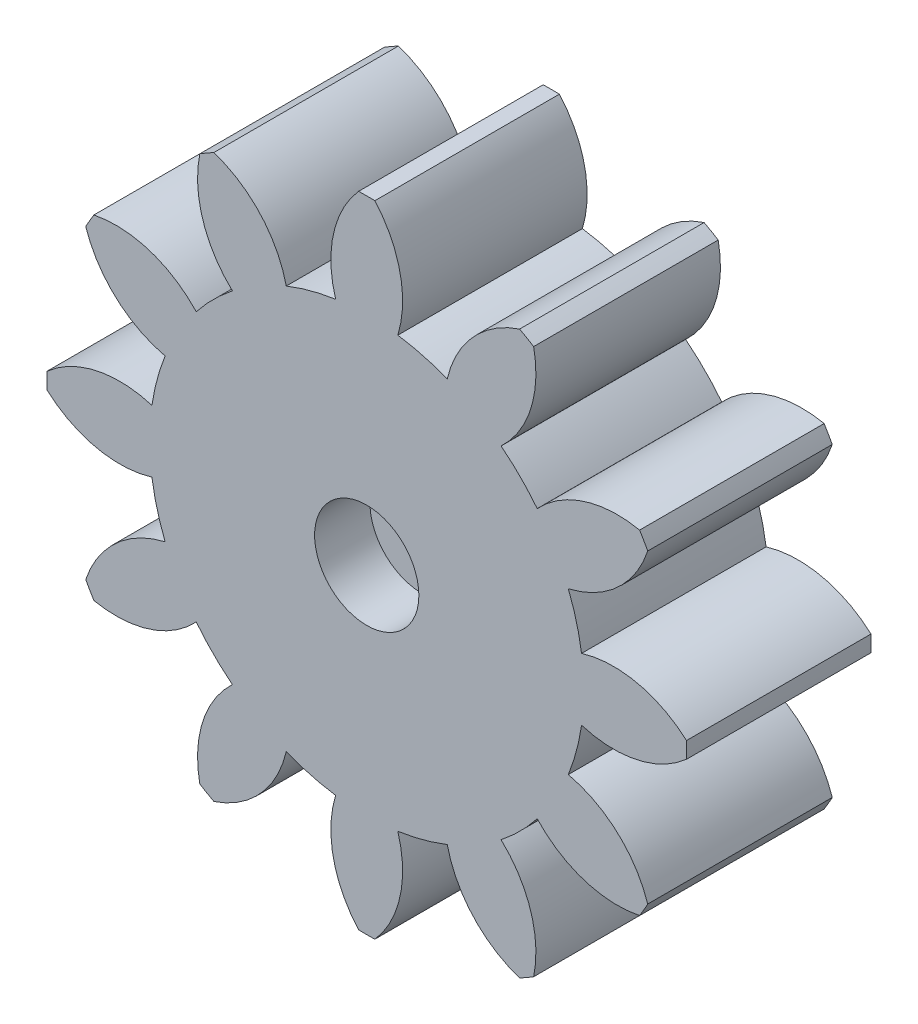
from build123d import *

# Parameters (mm, degrees)
BOSS_EXTRUDE1_DEPTH = 10
SKETCH3_R           = 2.825
CUT_EXTRUDE1_DEPTH  = 3
SKETCH4_R           = 2.825
CUT_EXTRUDE2_DEPTH  = 5
CUT_EXTRUDE3_REACH  = 7
SKETCH5_R           = 1.375
CUT_EXTRUDE4_DEPTH  = 0.4


with BuildPart() as part:
    # Sketch1 → Boss-Extrude1 (new body)
    with BuildSketch(Plane.XY):
        with BuildLine():
            ThreePointArc((10.92443124, -4.361437941), (11.362069294, -3.044457292), (11.641553947, -1.685099566))
            ThreePointArc((11.641553947, -1.685099566), (14.648632583, -1.806960077), (17.329910897, -0.440168758))
            ThreePointArc((17.329910897, -0.440168758), (17.3355, 0), (17.329910897, 0.440168758))
            ThreePointArc((17.329910897, 0.440168758), (14.648632583, 1.806960077), (11.641553947, 1.685099566))
            ThreePointArc((11.641553947, 1.685099566), (11.362069294, 3.044457292), (10.92443124, 4.361437941))
            ThreePointArc((10.92443124, 4.361437941), (13.589567986, 5.759442961), (15.228227462, 8.283758122))
            ThreePointArc((15.228227462, 8.283758122), (15.012983387, 8.66775), (14.788058703, 9.046152775))
            ThreePointArc((14.788058703, 9.046152775), (11.782607909, 8.889189622), (9.239331674, 7.280116005))
            ThreePointArc((9.239331674, 7.280116005), (8.317612002, 8.317612002), (7.280116005, 9.239331674))
            ThreePointArc((7.280116005, 9.239331674), (8.889189622, 11.782607909), (9.046152775, 14.788058703))
            ThreePointArc((9.046152775, 14.788058703), (8.66775, 15.012983387), (8.283758122, 15.228227462))
            ThreePointArc((8.283758122, 15.228227462), (5.759442961, 13.589567986), (4.361437941, 10.92443124))
            ThreePointArc((4.361437941, 10.92443124), (3.044457292, 11.362069294), (1.685099566, 11.641553947))
            ThreePointArc((1.685099566, 11.641553947), (1.806960077, 14.648632583), (0.440168758, 17.329910897))
            ThreePointArc((0.440168758, 17.329910897), (0, 17.3355), (-0.440168758, 17.329910897))
            ThreePointArc((-0.440168758, 17.329910897), (-1.806960077, 14.648632583), (-1.685099566, 11.641553947))
            ThreePointArc((-1.685099566, 11.641553947), (-3.044457292, 11.362069294), (-4.361437941, 10.92443124))
            ThreePointArc((-4.361437941, 10.92443124), (-5.759442961, 13.589567986), (-8.283758122, 15.228227462))
            ThreePointArc((-8.283758122, 15.228227462), (-8.66775, 15.012983387), (-9.046152775, 14.788058703))
            ThreePointArc((-9.046152775, 14.788058703), (-8.889189622, 11.782607909), (-7.280116005, 9.239331674))
            ThreePointArc((-7.280116005, 9.239331674), (-8.317612002, 8.317612002), (-9.239331674, 7.280116005))
            ThreePointArc((-9.239331674, 7.280116005), (-11.782607909, 8.889189622), (-14.788058703, 9.046152775))
            ThreePointArc((-14.788058703, 9.046152775), (-15.012983387, 8.66775), (-15.228227462, 8.283758122))
            ThreePointArc((-15.228227462, 8.283758122), (-13.589567986, 5.759442961), (-10.92443124, 4.361437941))
            ThreePointArc((-10.92443124, 4.361437941), (-11.362069294, 3.044457292), (-11.641553947, 1.685099566))
            ThreePointArc((-11.641553947, 1.685099566), (-14.648632583, 1.806960077), (-17.329910897, 0.440168758))
            ThreePointArc((-17.329910897, 0.440168758), (-17.3355, 0), (-17.329910897, -0.440168758))
            ThreePointArc((-17.329910897, -0.440168758), (-14.648632583, -1.806960077), (-11.641553947, -1.685099566))
            ThreePointArc((-11.641553947, -1.685099566), (-11.362069294, -3.044457292), (-10.92443124, -4.361437941))
            ThreePointArc((-10.92443124, -4.361437941), (-13.589567986, -5.759442961), (-15.228227462, -8.283758122))
            ThreePointArc((-15.228227462, -8.283758122), (-15.012983387, -8.66775), (-14.788058703, -9.046152775))
            ThreePointArc((-14.788058703, -9.046152775), (-11.782607909, -8.889189622), (-9.239331674, -7.280116005))
            ThreePointArc((-9.239331674, -7.280116005), (-8.317612002, -8.317612002), (-7.280116005, -9.239331674))
            ThreePointArc((-7.280116005, -9.239331674), (-8.889189622, -11.782607909), (-9.046152775, -14.788058703))
            ThreePointArc((-9.046152775, -14.788058703), (-8.66775, -15.012983387), (-8.283758122, -15.228227462))
            ThreePointArc((-8.283758122, -15.228227462), (-5.759442961, -13.589567986), (-4.361437941, -10.92443124))
            ThreePointArc((-4.361437941, -10.92443124), (-3.044457292, -11.362069294), (-1.685099566, -11.641553947))
            ThreePointArc((-1.685099566, -11.641553947), (-1.806960077, -14.648632583), (-0.440168758, -17.329910897))
            ThreePointArc((-0.440168758, -17.329910897), (0, -17.3355), (0.440168758, -17.329910897))
            ThreePointArc((0.440168758, -17.329910897), (1.806960077, -14.648632583), (1.685099566, -11.641553947))
            ThreePointArc((1.685099566, -11.641553947), (3.044457292, -11.362069294), (4.361437941, -10.92443124))
            ThreePointArc((4.361437941, -10.92443124), (5.759442961, -13.589567986), (8.283758122, -15.228227462))
            ThreePointArc((8.283758122, -15.228227462), (8.66775, -15.012983387), (9.046152775, -14.788058703))
            ThreePointArc((9.046152775, -14.788058703), (8.889189622, -11.782607909), (7.280116005, -9.239331674))
            ThreePointArc((7.280116005, -9.239331674), (8.317612002, -8.317612002), (9.239331674, -7.280116005))
            ThreePointArc((9.239331674, -7.280116005), (11.782607909, -8.889189622), (14.788058703, -9.046152775))
            ThreePointArc((14.788058703, -9.046152775), (15.012983387, -8.66775), (15.228227462, -8.283758122))
            ThreePointArc((15.228227462, -8.283758122), (13.589567986, -5.759442961), (10.92443124, -4.361437941))
        make_face()
    extrude(amount=BOSS_EXTRUDE1_DEPTH)

    # Sketch3 → Cut-Extrude1 (cut)
    with BuildSketch(Plane.XY.offset(10)):
        Circle(SKETCH3_R)
    extrude(amount=-CUT_EXTRUDE1_DEPTH, mode=Mode.SUBTRACT)

    # Sketch4 → Cut-Extrude2 (cut)
    with BuildSketch(Plane(origin=(0, 0, 0), x_dir=(-1, 0, 0), z_dir=(0, 0, -1))):
        Circle(SKETCH4_R)
    extrude(amount=-CUT_EXTRUDE2_DEPTH, mode=Mode.SUBTRACT)

    # Sketch5 → Cut-Extrude3 (cut, up to next)
    with BuildSketch(Plane(origin=(0, 0, 5), x_dir=(-1, 0, 0), z_dir=(0, 0, -1)), mode=Mode.PRIVATE) as cut_extrude3_sk1:
        Circle(SKETCH5_R)
    cut_extrude3_tool1 = extrude(cut_extrude3_sk1.sketch, amount=-CUT_EXTRUDE3_REACH, mode=Mode.PRIVATE) & part.part
    add(cut_extrude3_tool1.solids().sort_by_distance((0, 0, 5))[0], mode=Mode.SUBTRACT)

    # Sketch6 → Cut-Extrude4 (cut)
    with BuildSketch(Plane(origin=(0, 0, 0), x_dir=(-1, 0, 0), z_dir=(0, 0, -1))):
        with BuildLine():
            add(Edge.make_bspline(
                [(-5.479737052, 4.373698183), (-5.446887427, 4.37193719), (-5.382752567, 4.36849907), (-5.291014853, 4.340523863), (-5.207118443, 4.295161515), (-5.134075042, 4.232274652), (-5.071791468, 4.158364543), (-5.026849631, 4.074631791), (-5.000271189, 3.983493218), (-4.996560504, 3.920674078), (-4.994667607, 3.888628738)],
                knots=[0, 0, 0, 0, 9.839e-05, 0.000192094, 0.000284968, 0.000382609, 0.000479502, 0.000573402, 0.000665658, 0.000761727, 0.000761727, 0.000761727, 0.000761727], degree=3))
            add(Edge.make_bspline(
                [(-4.994667607, 3.888628738), (-4.996560504, 3.856583398), (-5.000271189, 3.793764258), (-5.026849631, 3.702625685), (-5.071791468, 3.618892933), (-5.134075042, 3.544982824), (-5.207118443, 3.482095961), (-5.291014853, 3.436733614), (-5.382752567, 3.408758407), (-5.446887427, 3.405320286), (-5.479737052, 3.403559294)],
                knots=[0, 0, 0, 0, 9.6069e-05, 0.000188325, 0.000282225, 0.000379118, 0.000476759, 0.000569633, 0.000663337, 0.000761727, 0.000761727, 0.000761727, 0.000761727], degree=3))
            add(Edge.make_bspline(
                [(-5.479737052, 3.403559294), (-5.512586676, 3.405320286), (-5.576721536, 3.408758407), (-5.66845925, 3.436733614), (-5.75235566, 3.482095961), (-5.825399061, 3.544982824), (-5.887682635, 3.618892933), (-5.932624473, 3.702625685), (-5.959202914, 3.793764258), (-5.962913599, 3.856583398), (-5.964806496, 3.888628738)],
                knots=[0, 0, 0, 0, 9.839e-05, 0.000192094, 0.000284968, 0.000382609, 0.000479502, 0.000573402, 0.000665658, 0.000761727, 0.000761727, 0.000761727, 0.000761727], degree=3))
            add(Edge.make_bspline(
                [(-5.964806496, 3.888628738), (-5.962913599, 3.920674078), (-5.959202914, 3.983493218), (-5.932624473, 4.074631791), (-5.887682635, 4.158364543), (-5.825399061, 4.232274652), (-5.75235566, 4.295161515), (-5.66845925, 4.340523863), (-5.576721536, 4.36849907), (-5.512586676, 4.37193719), (-5.479737052, 4.373698183)],
                knots=[0, 0, 0, 0, 9.6069e-05, 0.000188325, 0.000282225, 0.000379118, 0.000476759, 0.000569633, 0.000663337, 0.000761727, 0.000761727, 0.000761727, 0.000761727], degree=3))
        make_face()
        with BuildLine():
            Line((-1.076799017, 9.448270832), (-0.688510255, 9.128777977))
            Line((-0.688510255, 9.128777977), (-2.339612018, 7.287612946))
            add(Edge.make_bspline(
                [(-2.339612018, 7.287612946), (-2.293475941, 7.298663014), (-2.204016149, 7.320089558), (-2.071975602, 7.342137815), (-1.946936879, 7.355531186), (-1.86584402, 7.357693408), (-1.826557798, 7.358740918)],
                knots=[0, 0, 0, 0, 0.000142285, 0.000275896, 0.000401319, 0.00051918, 0.00051918, 0.00051918, 0.00051918], degree=3))
            add(Edge.make_bspline(
                [(-1.826557798, 7.358740918), (-1.770106051, 7.3576469), (-1.658257771, 7.355479314), (-1.493323714, 7.330537107), (-1.333006052, 7.294053504), (-1.178082765, 7.240843886), (-1.028341511, 7.173253389), (-0.884280505, 7.089457841), (-0.744574136, 6.991544564), (-0.657914346, 6.915703131), (-0.613884187, 6.87716957)],
                knots=[0, 0, 0, 0, 0.000169219, 0.000335276, 0.000499322, 0.000661936, 0.000825796, 0.000991397, 0.001161242, 0.001336667, 0.001336667, 0.001336667, 0.001336667], degree=3))
            add(Edge.make_bspline(
                [(-0.613884187, 6.87716957), (-0.564645567, 6.82916805), (-0.4674712, 6.734435149), (-0.340851546, 6.576386092), (-0.232593766, 6.408458965), (-0.146599008, 6.228517813), (-0.078095879, 6.039173053), (-0.029580923, 5.83944399), (0.000538682, 5.628879844), (0.003675046, 5.485030903), (0.005278974, 5.411466946)],
                knots=[0, 0, 0, 0, 0.000206134, 0.000406813, 0.000606065, 0.000804239, 0.001003781, 0.001209098, 0.001419844, 0.001640422, 0.001640422, 0.001640422, 0.001640422], degree=3))
            add(Edge.make_bspline(
                [(0.005278974, 5.411466946), (0.003413486, 5.339099327), (-0.000250432, 5.196965424), (-0.026935282, 4.988204371), (-0.074286977, 4.788932864), (-0.138337046, 4.598290395), (-0.220203443, 4.41571157), (-0.322431314, 4.243212413), (-0.441818271, 4.078798079), (-0.578847737, 3.926382509), (-0.728525887, 3.786840547), (-0.888113663, 3.663794775), (-1.057192775, 3.560563517), (-1.23473037, 3.476203118), (-1.420391917, 3.409034216), (-1.615252858, 3.362988048), (-1.818297659, 3.333988211), (-1.956664364, 3.330638678), (-2.027115357, 3.328933225)],
                knots=[0, 0, 0, 0, 0.000217083, 0.000426362, 0.000630001, 0.000830592, 0.001028903, 0.001229084, 0.00143106, 0.001637511, 0.001842948, 0.002044216, 0.002240996, 0.002436058, 0.00263301, 0.002832112, 0.003035767, 0.003247025, 0.003247025, 0.003247025, 0.003247025], degree=3))
            add(Edge.make_bspline(
                [(-2.027115357, 3.328933225), (-2.094055186, 3.330351861), (-2.225725255, 3.333142305), (-2.418998788, 3.359627061), (-2.603951524, 3.402174978), (-2.780094089, 3.463947737), (-2.948685764, 3.540355538), (-3.108298364, 3.635834193), (-3.259006003, 3.748482891), (-3.400412097, 3.876015749), (-3.529536875, 4.016063086), (-3.641533768, 4.166879142), (-3.736970041, 4.325759748), (-3.815735842, 4.492638821), (-3.874910321, 4.669011891), (-3.917959765, 4.853244465), (-3.945974558, 5.045641563), (-3.948581584, 5.176996452), (-3.94990265, 5.243558292)],
                knots=[0, 0, 0, 0, 0.000200724, 0.000394822, 0.000584039, 0.000769155, 0.00095386, 0.001138436, 0.001325935, 0.001517477, 0.001708941, 0.00189644, 0.002080016, 0.002264153, 0.002448891, 0.002636973, 0.002831228, 0.003030787, 0.003030787, 0.003030787, 0.003030787], degree=3))
            add(Edge.make_bspline(
                [(-3.94990265, 5.243558292), (-3.946936348, 5.331199106), (-3.941018644, 5.506040511), (-3.894628631, 5.765739123), (-3.821120222, 6.020647374), (-3.734859718, 6.230669955), (-3.645000711, 6.401562402), (-3.560616011, 6.542892784), (-3.458404673, 6.695733373), (-3.339328838, 6.860364287), (-3.205193555, 7.038254894), (-3.053233575, 7.22697045), (-2.883776647, 7.427332085), (-2.764246075, 7.564134189), (-2.702248069, 7.635090577)],
                knots=[0, 0, 0, 0, 0.000262795, 0.00052427, 0.000788866, 0.001057593, 0.001203627, 0.001367806, 0.001551173, 0.001755039, 0.001977287, 0.002219485, 0.002481801, 0.002764476, 0.002764476, 0.002764476, 0.002764476], degree=3))
            Line((-2.702248069, 7.635090577), (-1.076799017, 9.448270832))
        make_face()
        with BuildLine():
            add(Edge.make_bspline(
                [(-1.938496901, 6.836358439), (-1.989106854, 6.835080646), (-2.088829894, 6.832562853), (-2.235616293, 6.810571268), (-2.377171442, 6.776633185), (-2.511970541, 6.724830877), (-2.642423486, 6.662929855), (-2.764906112, 6.582928302), (-2.883851086, 6.492195139), (-2.994052185, 6.386733353), (-3.095326481, 6.271819283), (-3.18467958, 6.149221081), (-3.259059194, 6.01898642), (-3.32207734, 5.882849259), (-3.369200206, 5.73949883), (-3.403566116, 5.589666528), (-3.423283173, 5.433372874), (-3.426093982, 5.326789138), (-3.427520171, 5.2727091)],
                knots=[0, 0, 0, 0, 0.000151746, 0.000299003, 0.000444365, 0.000587526, 0.000731459, 0.000876694, 0.001025495, 0.001179733, 0.001333411, 0.00148455, 0.001633953, 0.001782662, 0.001933842, 0.00208574, 0.00224324, 0.00240547, 0.00240547, 0.00240547, 0.00240547], degree=3))
            add(Edge.make_bspline(
                [(-3.427520171, 5.2727091), (-3.426673712, 5.222489912), (-3.425013104, 5.123968402), (-3.403894906, 4.980095456), (-3.373075898, 4.842411855), (-3.327923177, 4.711559643), (-3.273002753, 4.585863374), (-3.201397452, 4.468953107), (-3.119594659, 4.35731605), (-3.025944917, 4.253296228), (-2.922821423, 4.159646977), (-2.813489515, 4.077378741), (-2.699348501, 4.006467863), (-2.57819796, 3.951088172), (-2.453175813, 3.905948156), (-2.322499761, 3.875034323), (-2.187161622, 3.853916701), (-2.09482803, 3.852189652), (-2.048103939, 3.851315704)],
                knots=[0, 0, 0, 0, 0.000150531, 0.000295316, 0.000435328, 0.000573235, 0.00070998, 0.000845961, 0.000983558, 0.001124744, 0.001265066, 0.001400792, 0.00153478, 0.001667282, 0.001799682, 0.001932886, 0.00206959, 0.002209635, 0.002209635, 0.002209635, 0.002209635], degree=3))
            add(Edge.make_bspline(
                [(-2.048103939, 3.851315704), (-2.000229082, 3.852723802), (-1.905236709, 3.855517722), (-1.764664845, 3.875973142), (-1.627367147, 3.908929627), (-1.492976788, 3.9538632), (-1.362769143, 4.014570555), (-1.23530464, 4.08717845), (-1.110559165, 4.172150729), (-0.990999465, 4.269825632), (-0.879345803, 4.377748922), (-0.782373143, 4.497413501), (-0.699618368, 4.625385113), (-0.633480674, 4.762822478), (-0.580192722, 4.908316197), (-0.543443834, 5.062886425), (-0.520578903, 5.226156607), (-0.518280179, 5.337928519), (-0.517103505, 5.395142493)],
                knots=[0, 0, 0, 0, 0.000143593, 0.000284914, 0.000425192, 0.000566787, 0.000709224, 0.000855444, 0.00100648, 0.001161457, 0.001318122, 0.001471459, 0.001622508, 0.001774263, 0.001928078, 0.002086452, 0.002250038, 0.002421587, 0.002421587, 0.002421587, 0.002421587], degree=3))
            add(Edge.make_bspline(
                [(-0.517103505, 5.395142493), (-0.518607886, 5.445332005), (-0.521557199, 5.543727699), (-0.540034472, 5.688402254), (-0.573079796, 5.826541604), (-0.618329417, 5.958766548), (-0.677324159, 6.084411207), (-0.74868433, 6.204332372), (-0.834241359, 6.317035782), (-0.930607988, 6.422864665), (-1.036317017, 6.518848832), (-1.147884871, 6.604829915), (-1.266467662, 6.675797162), (-1.389954416, 6.735181507), (-1.519559137, 6.780177032), (-1.654149192, 6.813330675), (-1.794557359, 6.831924669), (-1.889859834, 6.834860271), (-1.938496901, 6.836358439)],
                knots=[0, 0, 0, 0, 0.000150581, 0.000295211, 0.000436623, 0.000576012, 0.000713727, 0.000852309, 0.000993865, 0.001137481, 0.001281097, 0.001421724, 0.001559306, 0.001694912, 0.001832098, 0.001970109, 0.002110116, 0.002256038, 0.002256038, 0.002256038, 0.002256038], degree=3))
        make_face(mode=Mode.SUBTRACT)
        with BuildLine():
            Line((2.318687094, 9.299018695), (4.632095213, 9.299018695))
            Line((4.632095213, 9.299018695), (4.557469145, 8.776636217))
            Line((4.557469145, 8.776636217), (2.697647597, 8.776636217))
            Line((2.697647597, 8.776636217), (2.251057219, 7.338918368))
            add(Edge.make_bspline(
                [(2.251057219, 7.338918368), (2.281376529, 7.341600763), (2.338895932, 7.346689591), (2.420795645, 7.354528554), (2.493562715, 7.35783457), (2.539065408, 7.358454804), (2.560055784, 7.358740918)],
                knots=[0, 0, 0, 0, 9.1316e-05, 0.000173238, 0.000246781, 0.000309757, 0.000309757, 0.000309757, 0.000309757], degree=3))
            add(Edge.make_bspline(
                [(2.560055784, 7.358740918), (2.629097715, 7.35583168), (2.767128952, 7.350015421), (2.970788893, 7.302493959), (3.168952118, 7.225239078), (3.360529688, 7.119781499), (3.53938682, 6.985546631), (3.702452922, 6.826913065), (3.843878862, 6.641785132), (3.964293972, 6.434712765), (4.061524524, 6.210786548), (4.13377311, 5.974414215), (4.176421409, 5.727065278), (4.181678325, 5.558550488), (4.184338803, 5.473266659)],
                knots=[0, 0, 0, 0, 0.000206944, 0.00041373, 0.000623774, 0.00084349, 0.001067602, 0.001292706, 0.001523834, 0.001764218, 0.002009653, 0.002254581, 0.002504169, 0.002759913, 0.002759913, 0.002759913, 0.002759913], degree=3))
            add(Edge.make_bspline(
                [(4.184338803, 5.473266659), (4.183352396, 5.425044423), (4.181384142, 5.328822907), (4.168335693, 5.185904094), (4.147071445, 5.045028829), (4.118617764, 4.906498732), (4.079215817, 4.770525235), (4.033093178, 4.636774893), (3.977719486, 4.505165198), (3.914322211, 4.376993978), (3.843116583, 4.254002982), (3.767708057, 4.137272529), (3.68682921, 4.028109415), (3.600394249, 3.926387748), (3.508424649, 3.832148967), (3.411440499, 3.745092909), (3.308255088, 3.667302411), (3.201178697, 3.595722898), (3.089091634, 3.533023925), (2.973952909, 3.478072585), (2.855038284, 3.432100729), (2.732755614, 3.395607611), (2.607362982, 3.364211073), (2.478231713, 3.343658369), (2.345716485, 3.332140741), (2.2565206, 3.330010526), (2.21141212, 3.328933225)],
                knots=[0, 0, 0, 0, 0.000144663, 0.000288658, 0.000430147, 0.000571934, 0.00071256, 0.000854534, 0.000996163, 0.001140609, 0.001283214, 0.001422285, 0.001557313, 0.001690491, 0.001822423, 0.001952084, 0.00208105, 0.002209763, 0.002338196, 0.002465982, 0.002592226, 0.002720219, 0.002848615, 0.002979736, 0.003112012, 0.003247352, 0.003247352, 0.003247352, 0.003247352], degree=3))
            add(Edge.make_bspline(
                [(2.21141212, 3.328933225), (2.16396587, 3.329851256), (2.070030352, 3.331668801), (1.931137364, 3.345473936), (1.796968333, 3.3706609), (1.666418728, 3.402720758), (1.540655136, 3.446233136), (1.41893022, 3.498665311), (1.301845272, 3.561106939), (1.188254643, 3.632011908), (1.079602645, 3.714150269), (0.975266388, 3.806692457), (0.876181435, 3.910433424), (0.783132268, 4.026241385), (0.69169693, 4.150156429), (0.606678686, 4.286533432), (0.526100484, 4.433320564), (0.477729789, 4.536657942), (0.453035384, 4.589414161)],
                knots=[0, 0, 0, 0, 0.000142332, 0.000281794, 0.000418105, 0.000551589, 0.000684706, 0.000816838, 0.000948806, 0.001082418, 0.001218144, 0.001356907, 0.001500409, 0.00164792, 0.001802317, 0.001962132, 0.002129639, 0.00230435, 0.00230435, 0.00230435, 0.00230435], degree=3))
            Line((0.453035384, 4.589414161), (0.988244218, 4.821454593))
            add(Edge.make_bspline(
                [(0.988244218, 4.821454593), (1.005255878, 4.78236131), (1.038712367, 4.705477339), (1.096059706, 4.596306995), (1.156748465, 4.494026152), (1.222163227, 4.399319237), (1.291904013, 4.312040812), (1.365787196, 4.231960872), (1.444101322, 4.159872477), (1.551444797, 4.073166135), (1.695405641, 3.986057221), (1.876162682, 3.907244777), (2.065596651, 3.859959615), (2.194442019, 3.854207566), (2.259219445, 3.851315704)],
                knots=[0, 0, 0, 0, 0.000127865, 0.00025147, 0.000369655, 0.000484478, 0.000596471, 0.000704561, 0.000811002, 0.00091553, 0.001118114, 0.00131348, 0.001505507, 0.001699661, 0.001699661, 0.001699661, 0.001699661], degree=3))
            add(Edge.make_bspline(
                [(2.259219445, 3.851315704), (2.303208236, 3.85274706), (2.390465379, 3.855586331), (2.519614288, 3.875711184), (2.645208809, 3.910164662), (2.768426821, 3.956964553), (2.888689814, 4.017477291), (3.004576765, 4.093412356), (3.117887536, 4.18130084), (3.228001329, 4.280525189), (3.330749603, 4.391340263), (3.419183478, 4.514347811), (3.494597313, 4.646422495), (3.556720693, 4.787305529), (3.602692959, 4.938704792), (3.638342764, 5.097947009), (3.657801791, 5.267564902), (3.660546567, 5.38343647), (3.661956324, 5.442949819)],
                knots=[0, 0, 0, 0, 0.000131947, 0.000261734, 0.000391, 0.000522017, 0.000656556, 0.000794014, 0.000936985, 0.001086406, 0.001238259, 0.001389398, 0.001539812, 0.001693843, 0.001850213, 0.002013745, 0.002182819, 0.00236136, 0.00236136, 0.00236136, 0.00236136], degree=3))
            add(Edge.make_bspline(
                [(3.661956324, 5.442949819), (3.660787094, 5.493134291), (3.658487659, 5.591828159), (3.641907231, 5.736105749), (3.615435234, 5.87357755), (3.577227029, 6.003444193), (3.526138201, 6.125606727), (3.465979554, 6.24117438), (3.394202788, 6.349537486), (3.31159483, 6.449071773), (3.221073681, 6.5396656), (3.124167776, 6.620132131), (3.019693798, 6.686036929), (2.910546784, 6.742226352), (2.794297431, 6.783737985), (2.672077661, 6.814136504), (2.543953066, 6.833398887), (2.456346825, 6.83536334), (2.411969679, 6.836358439)],
                knots=[0, 0, 0, 0, 0.000150531, 0.000296038, 0.000435075, 0.000570103, 0.000701327, 0.000831719, 0.000960433, 0.00109047, 0.001219094, 0.001344207, 0.001467443, 0.001588946, 0.001711778, 0.001836778, 0.001966391, 0.002099447, 0.002099447, 0.002099447, 0.002099447], degree=3))
            add(Edge.make_bspline(
                [(2.411969679, 6.836358439), (2.339135462, 6.833693433), (2.189851737, 6.828231138), (1.962219145, 6.788444284), (1.726127633, 6.726214825), (1.569961928, 6.665740044), (1.489638115, 6.634634848)],
                knots=[0, 0, 0, 0, 0.000218425, 0.000447692, 0.000691501, 0.000949719, 0.000949719, 0.000949719, 0.000949719], degree=3))
            Line((1.489638115, 6.634634848), (2.318687094, 9.299018695))
        make_face()
    extrude(amount=-CUT_EXTRUDE4_DEPTH, mode=Mode.SUBTRACT)


solid = part.part
